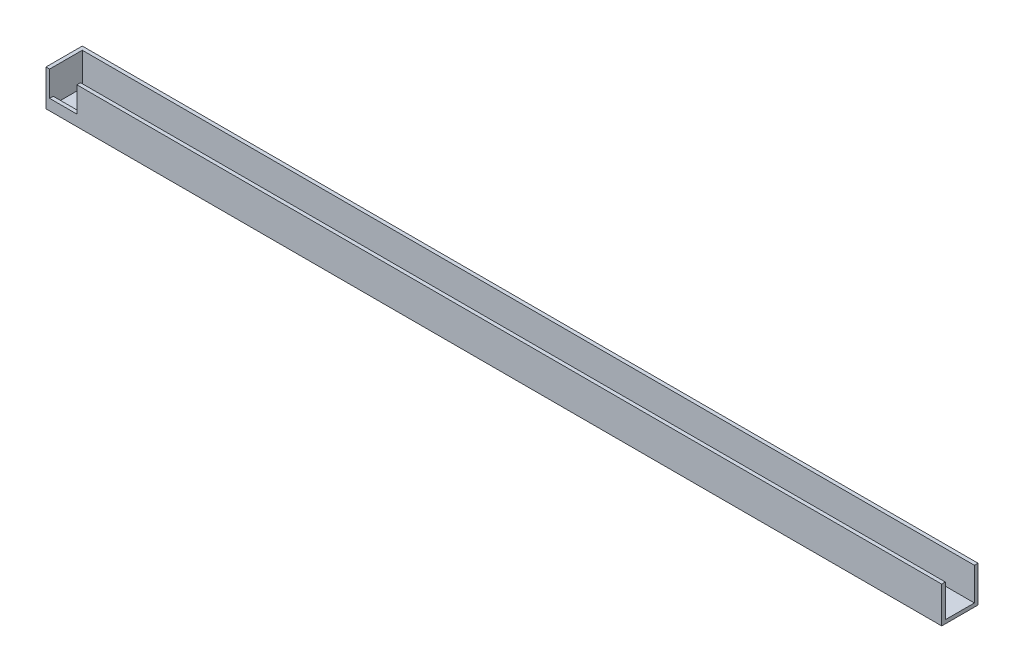
from build123d import *

# Parameters (mm, degrees)
SKETCH1_W           = 1568.45
SKETCH1_H           = 63.5
BOSS_EXTRUDE1_DEPTH = 63.5
SHELL1_T            = -6.35
SKETCH3_W           = 47.752
SKETCH3_H           = 44.45
CUT_EXTRUDE1_DEPTH  = 6.35


with BuildPart() as part:
    # Sketch1 → Boss-Extrude1 (new body)
    with BuildSketch(Plane.XY):
        with Locations((0, 31.75)):
            Rectangle(SKETCH1_W, SKETCH1_H)
    extrude(amount=BOSS_EXTRUDE1_DEPTH)

    # Shell1
    shell1_openings = [part.faces().sort_by_distance(p)[0] for p in [
        (0, 63.5, 31.75),
        (784.225, 31.75, 31.75),
    ]]
    offset(amount=SHELL1_T, openings=shell1_openings, kind=Kind.INTERSECTION)

    # Sketch3 → Cut-Extrude1 (cut)
    with BuildSketch(Plane.XY.offset(63.5)):
        with Locations((-753.999, 41.275)):
            Rectangle(SKETCH3_W, SKETCH3_H)
    extrude(amount=-CUT_EXTRUDE1_DEPTH, mode=Mode.SUBTRACT)


solid = part.part
